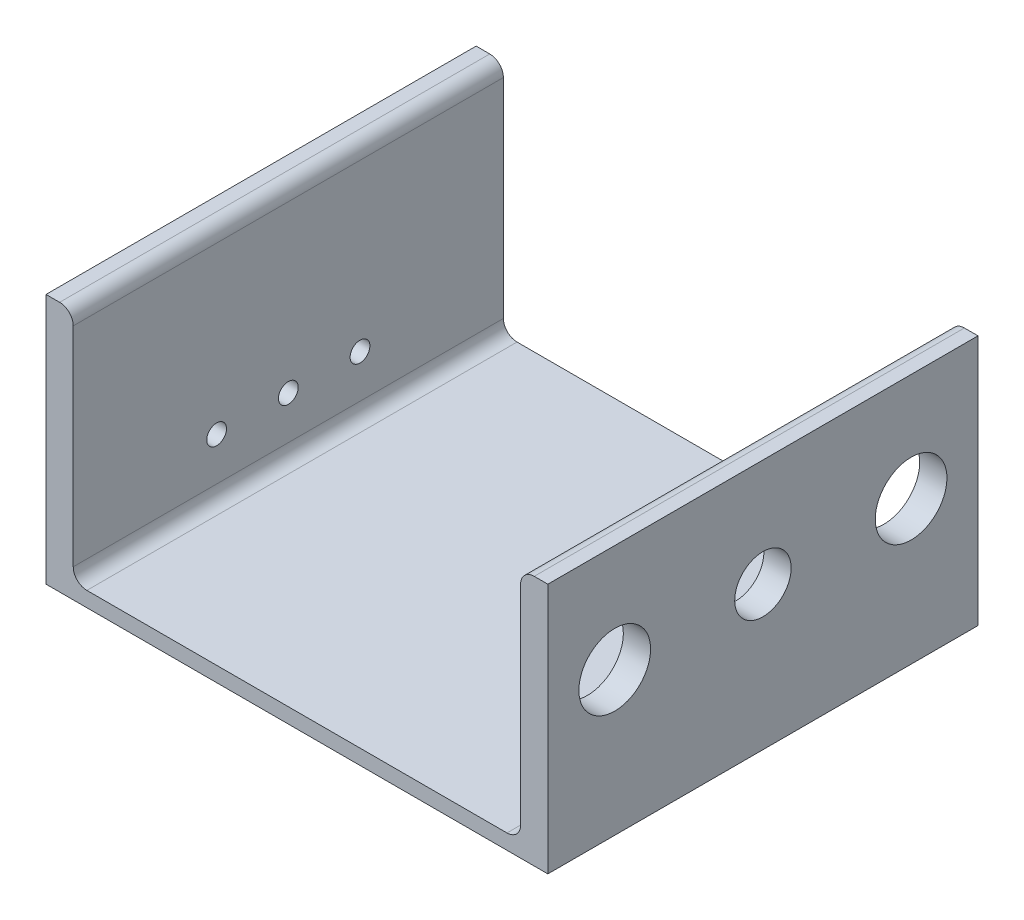
from build123d import *

# Parameters (mm, degrees)
BOSS_EXTRUDE1_DEPTH = 76.2
FILLET1_R           = 4.826
SKETCH2_R           = 12.7
SKETCH2_R_2         = 10
CUT_EXTRUDE1_DEPTH  = 9.652
SKETCH3_R           = 3.5
CUT_EXTRUDE2_DEPTH  = 9.652


with BuildPart() as part:
    # Sketch1 → Boss-Extrude1 (new body, symmetric)
    with BuildSketch(Plane.XY):
        Polygon((-79.248, 88.9), (-88.9, 88.9), (-88.9, 0), (88.9, 0), (88.9, 88.9), (79.248, 88.9), (79.248, 5.334), (-79.248, 5.334), align=None)
    extrude(amount=BOSS_EXTRUDE1_DEPTH, both=True)

    # Fillet1
    fillet1_edges = [part.edges().sort_by_distance(p)[0] for p in [
        (-79.248, 5.334, 0),
        (79.248, 5.334, 0),
        (79.248, 88.9, 0),
        (-79.248, 88.9, 0),
    ]]
    fillet(fillet1_edges, radius=FILLET1_R)

    # Sketch2 → Cut-Extrude1 (cut)
    with BuildSketch(Plane(origin=(88.9, 0, 0), x_dir=(0, 0, -1), z_dir=(1, 0, 0))):
        with Locations((52.5, 50.8)):
            Circle(SKETCH2_R)
        with Locations((-52.5, 50.8)):
            Circle(SKETCH2_R)
        with Locations((0, 50.8)):
            Circle(SKETCH2_R_2)
    extrude(amount=-CUT_EXTRUDE1_DEPTH, mode=Mode.SUBTRACT)

    # Sketch3 → Cut-Extrude2 (cut)
    with BuildSketch(Plane.ZY.offset(88.9)):
        with Locations((-25.4, 25.4)):
            Circle(SKETCH3_R)
        with Locations((25.4, 25.4)):
            Circle(SKETCH3_R)
        with Locations((0, 25.4)):
            Circle(SKETCH3_R)
    extrude(amount=-CUT_EXTRUDE2_DEPTH, mode=Mode.SUBTRACT)


solid = part.part
